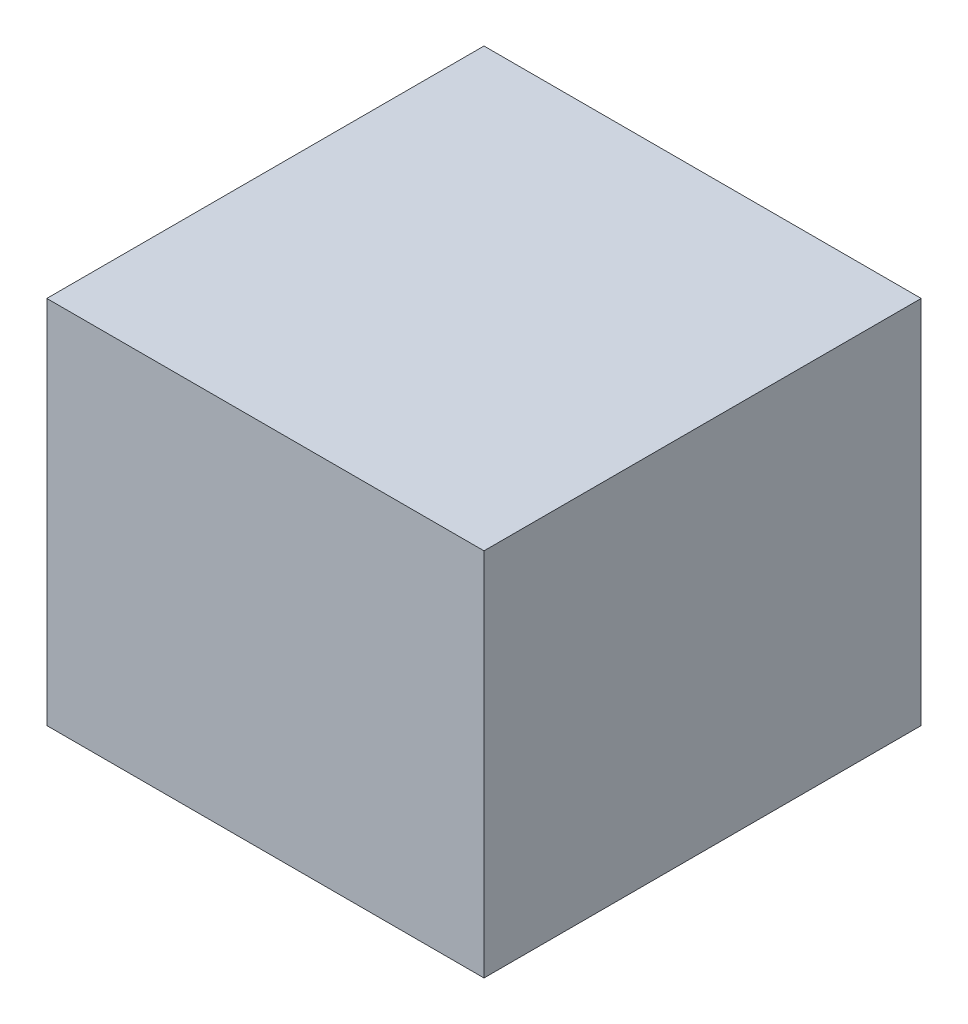
from build123d import *

# Parameters (mm, degrees)
SKETCH1_W           = 330.2
SKETCH1_H           = 330.2
BOSS_EXTRUDE1_DEPTH = 279.4


with BuildPart() as part:
    # Sketch1 → Boss-Extrude1 (new body)
    with BuildSketch(Plane(origin=(0, 0, 0), x_dir=(1, 0, 0), z_dir=(0, 1, 0))):
        Rectangle(SKETCH1_W, SKETCH1_H)
    extrude(amount=BOSS_EXTRUDE1_DEPTH)


solid = part.part
